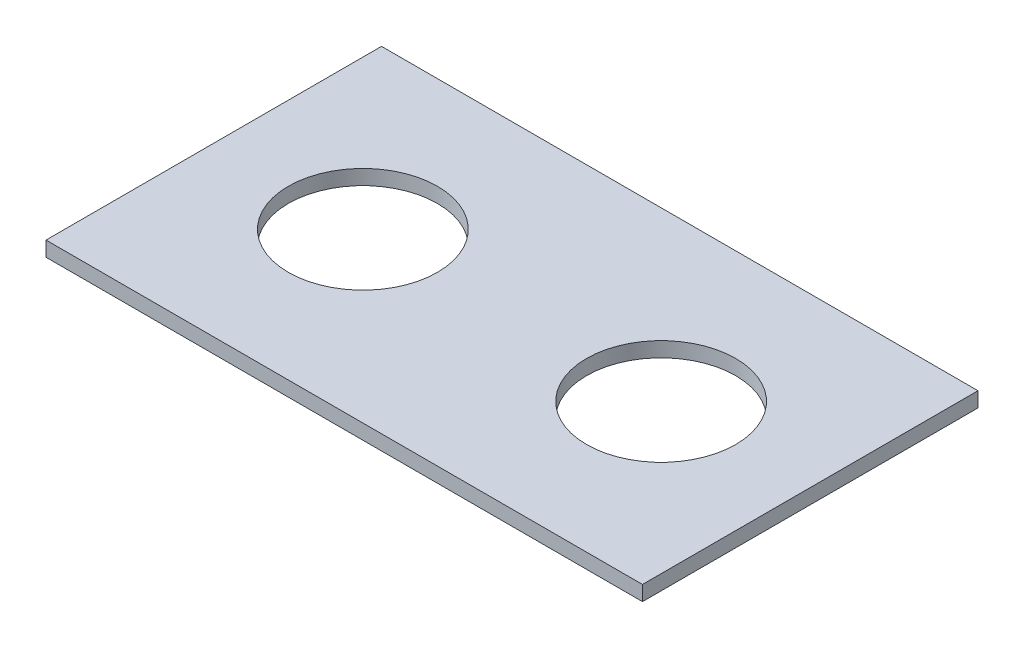
from build123d import *

# Parameters (mm, degrees)
SKETCH1_W           = 101.6
SKETCH1_H           = 57.15
BOSS_EXTRUDE1_DEPTH = 2.54
SKETCH2_R           = 12.7
CUT_EXTRUDE1_DEPTH  = 2.54


with BuildPart() as part:
    # Sketch1 → Boss-Extrude1 (new body)
    with BuildSketch(Plane(origin=(0, 0, 0), x_dir=(1, 0, 0), z_dir=(0, 1, 0))):
        Rectangle(SKETCH1_W, SKETCH1_H)
    extrude(amount=BOSS_EXTRUDE1_DEPTH)

    # Sketch2 → Cut-Extrude1 (cut)
    with BuildSketch(Plane(origin=(0, 2.54, 0), x_dir=(1, 0, 0), z_dir=(0, 1, 0))):
        with Locations((-25.4, 0)):
            Circle(SKETCH2_R)
        with Locations((25.4, 0)):
            Circle(SKETCH2_R)
    extrude(amount=-CUT_EXTRUDE1_DEPTH, mode=Mode.SUBTRACT)


solid = part.part
